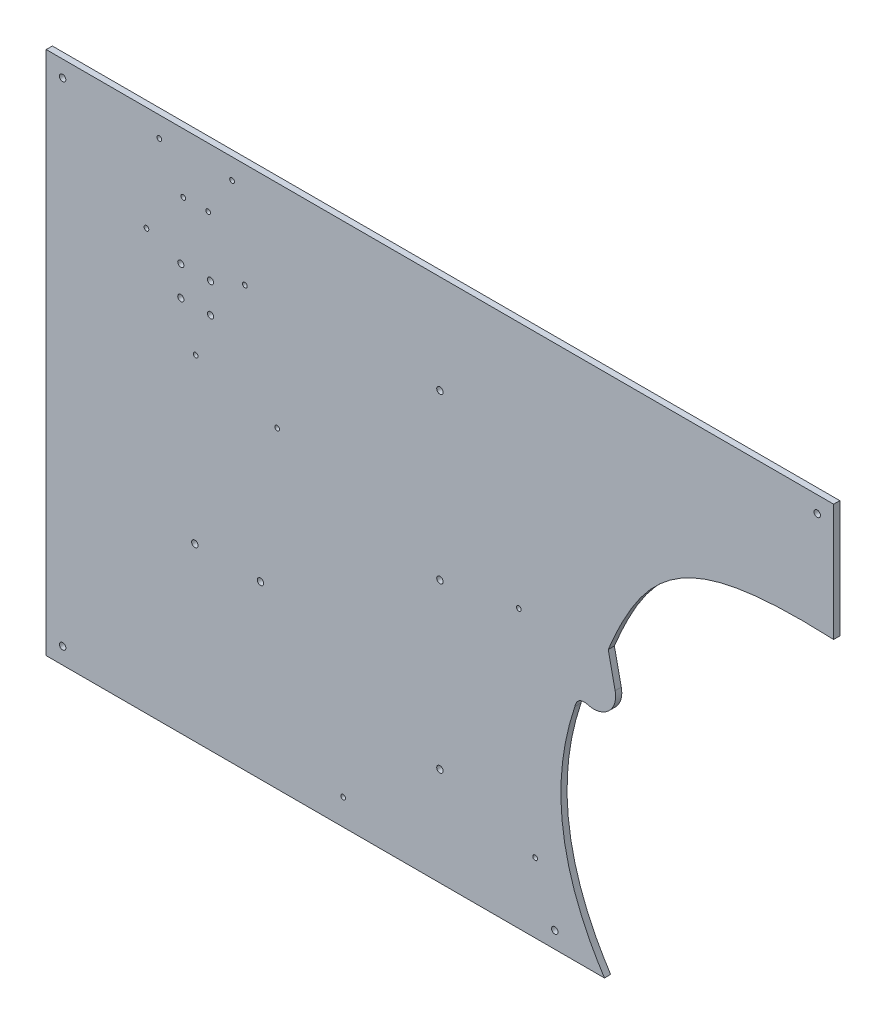
from build123d import *

# Parameters (mm, degrees)
SKETCH1_W                          = 609.6
SKETCH1_H                          = 406.4
BOSS_EXTRUDE1_DEPTH                = 4.7625
F_10_CLEARANCE_HOLE1_D             = 4.9784
F_10_CLEARANCE_HOLE1_DEPTH         = 10.16
F_10_CLEARANCE_HOLE1_TIP           = 1.495662253
F_6_CLEARANCE_HOLE1_D              = 3.6576
F_6_CLEARANCE_HOLE1_DEPTH          = 10.16
F_6_CLEARANCE_HOLE1_TIP            = 1.0988539
F_10_CLEARANCE_HOLE2_D             = 4.9784
F_10_CLEARANCE_HOLE2_DEPTH         = 10.16
F_10_CLEARANCE_HOLE2_TIP           = 1.495662253
CUT_EXTRUDE6_DEPTH                 = 5.7625
F_3_16_0_1875_DIAMETER_HOLE1_D     = 4.7625
F_3_16_0_1875_DIAMETER_HOLE1_DEPTH = 10.16
F_3_16_0_1875_DIAMETER_HOLE1_TIP   = 1.430799349


with BuildPart() as part:
    # Sketch1 → Boss-Extrude1 (new body)
    with BuildSketch(Plane.XY):
        with Locations((304.8, 203.2)):
            Rectangle(SKETCH1_W, SKETCH1_H)
    extrude(amount=BOSS_EXTRUDE1_DEPTH)

    # #10 Clearance Hole1
    with Locations(Plane.XY.offset(4.7625)):
        with Locations((393.7, 12.7), (304.8, 203.2), (596.9, 393.7), (12.7, 12.7), (12.7, 393.7), (596.9, 12.7), (304.8, 330.2), (304.8, 76.2)):
            Hole(F_10_CLEARANCE_HOLE1_D / 2, depth=F_10_CLEARANCE_HOLE1_DEPTH)
            with Locations((0, 0, -(F_10_CLEARANCE_HOLE1_DEPTH + F_10_CLEARANCE_HOLE1_TIP / 2))):  # 118° drill point
                Cone(0, F_10_CLEARANCE_HOLE1_D / 2, F_10_CLEARANCE_HOLE1_TIP, mode=Mode.SUBTRACT)

    # #6 Clearance Hole1
    with Locations(Plane.XY.offset(4.7625)):
        with Locations((153.8, 325.397045256), (115.7, 259.405909488), (77.6, 325.397045256), (178.748637136, 241.986495315), (365.913011093, 214.603454564), (378.514626904, 53.804869065), (229.881403774, 20.131066458), (87.511505802, 390.539377284), (106.048, 360.365035489), (125.352, 360.365035489), (143.888494198, 390.539377284)):
            Hole(F_6_CLEARANCE_HOLE1_D / 2, depth=F_6_CLEARANCE_HOLE1_DEPTH)
            with Locations((0, 0, -(F_6_CLEARANCE_HOLE1_DEPTH + F_6_CLEARANCE_HOLE1_TIP / 2))):  # 118° drill point
                Cone(0, F_6_CLEARANCE_HOLE1_D / 2, F_6_CLEARANCE_HOLE1_TIP, mode=Mode.SUBTRACT)

    # #10 Clearance Hole2
    with Locations(Plane.XY.offset(4.7625)):
        with Locations((165.89375, 132.55625), (115.09375, 132.55625)):
            Hole(F_10_CLEARANCE_HOLE2_D / 2, depth=F_10_CLEARANCE_HOLE2_DEPTH)
            with Locations((0, 0, -(F_10_CLEARANCE_HOLE2_DEPTH + F_10_CLEARANCE_HOLE2_TIP / 2))):  # 118° drill point
                Cone(0, F_10_CLEARANCE_HOLE2_D / 2, F_10_CLEARANCE_HOLE2_TIP, mode=Mode.SUBTRACT)

    # Sketch14 → Cut-Extrude6 (cut, through all)
    with BuildSketch(Plane.XY):
        with BuildLine():
            Line((609.6, 315.642514433), (609.6, 0))
            Line((609.6, 0), (432.195867807, 0))
            add(Edge.make_bspline(
                [(409.29659152, 170.617944662), (389.336707443, 111.226571114), (396.96980279, 54.353932563), (432.195867807, 0)],
                knots=[0.116936562, 0.116936562, 0.116936562, 0.116936562, 1, 1, 1, 1], degree=3))
            add(Edge.make_bspline(
                [(418.07234083, 177.13057308), (410.929678592, 177.953538089), (409.29659152, 170.617944662)],
                knots=[0, 0, 0, 1, 1, 1], degree=2))
            ThreePointArc((418.07234083, 177.13057308), (435.035932656, 180.354053738), (440.45974614, 196.747238983))
            Line((440.45974614, 196.747238983), (435.086955617, 221.682561203))
            add(Edge.make_bspline(
                [(435.086955617, 221.682561203), (465.243862883, 294.790369183), (498.032190497, 320.641169761), (609.6, 315.642514433)],
                knots=[0.107898544, 0.107898544, 0.107898544, 0.107898544, 1, 1, 1, 1], degree=3))
        make_face()
    extrude(amount=CUT_EXTRUDE6_DEPTH, mode=Mode.SUBTRACT)

    # 3/16 (0.1875) Diameter Hole1
    with Locations(Plane.XY.offset(4.7625)):
        with Locations((127.2, 314.9), (127.2, 291.9), (104.2, 291.9), (104.2, 314.9)):
            Hole(F_3_16_0_1875_DIAMETER_HOLE1_D / 2, depth=F_3_16_0_1875_DIAMETER_HOLE1_DEPTH)
            with Locations((0, 0, -(F_3_16_0_1875_DIAMETER_HOLE1_DEPTH + F_3_16_0_1875_DIAMETER_HOLE1_TIP / 2))):  # 118° drill point
                Cone(0, F_3_16_0_1875_DIAMETER_HOLE1_D / 2, F_3_16_0_1875_DIAMETER_HOLE1_TIP, mode=Mode.SUBTRACT)


solid = part.part
